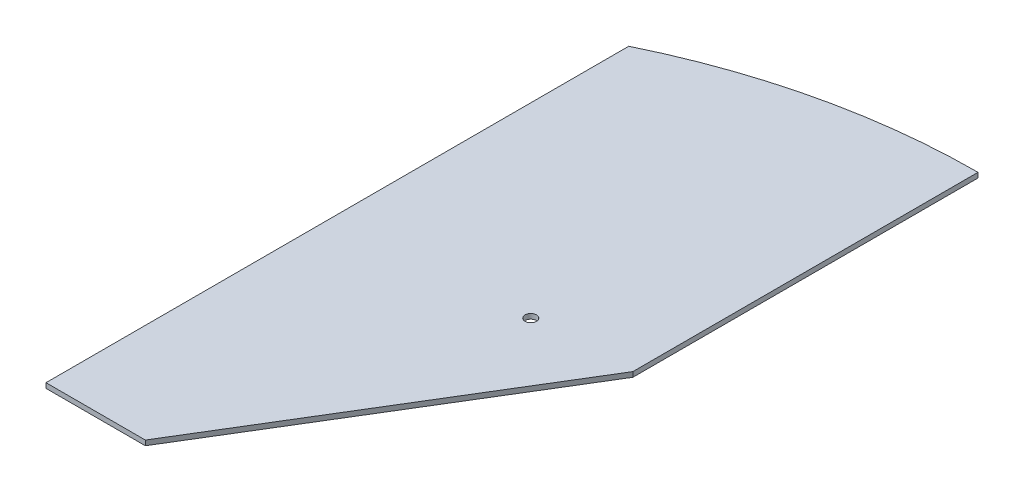
from build123d import *

# Parameters (mm, degrees)
BOSS_EXTRUDE1_DEPTH     = 0.35
SCALE1_SCALE            = 10
SKETCH2_R               = 4
CUT_EXTRUDE1_DEPTH      = 1
CUT_EXTRUDE1_DEPTH_BACK = 4.5


with BuildPart() as part:
    # Sketch1 → Boss-Extrude1 (new body)
    with BuildSketch(Plane(origin=(0, 0, 0), x_dir=(1, 0, 0), z_dir=(0, 1, 0))):
        with BuildLine():
            Line((-0.845785748, -19.220149774), (12.154214252, 2.13400673))
            Line((12.154214252, 2.13400673), (12.154214252, 26.456928478))
            ThreePointArc((12.154214252, 26.456928478), (1.891851134, 25.289168137), (-7.845785748, 21.84559602))
            Line((-7.845785748, 21.84559602), (-7.845785748, -19.220149774))
            Line((-7.845785748, -19.220149774), (-0.845785748, -19.220149774))
        make_face()
    extrude(amount=BOSS_EXTRUDE1_DEPTH)


with BuildPart() as part_1:
    # Scale1: scaled about (1.302109207, 0.175, -5.681101669)
    add(part.part.scale(SCALE1_SCALE).moved(Location((-11.718982863, -1.575, 51.129915021))))

    # Sketch2 → Cut-Extrude1 (cut, two sides)
    with BuildSketch(Plane(origin=(0, 1.925, 0), x_dir=(1, 0, 0), z_dir=(0, 1, 0))) as cut_extrude1_sk:
        with Locations((41.216468576, -33.118318866)):
            Circle(SKETCH2_R)
    extrude(amount=CUT_EXTRUDE1_DEPTH, mode=Mode.SUBTRACT)
    extrude(cut_extrude1_sk.sketch, amount=-CUT_EXTRUDE1_DEPTH_BACK, mode=Mode.SUBTRACT)


solid = part_1.part
